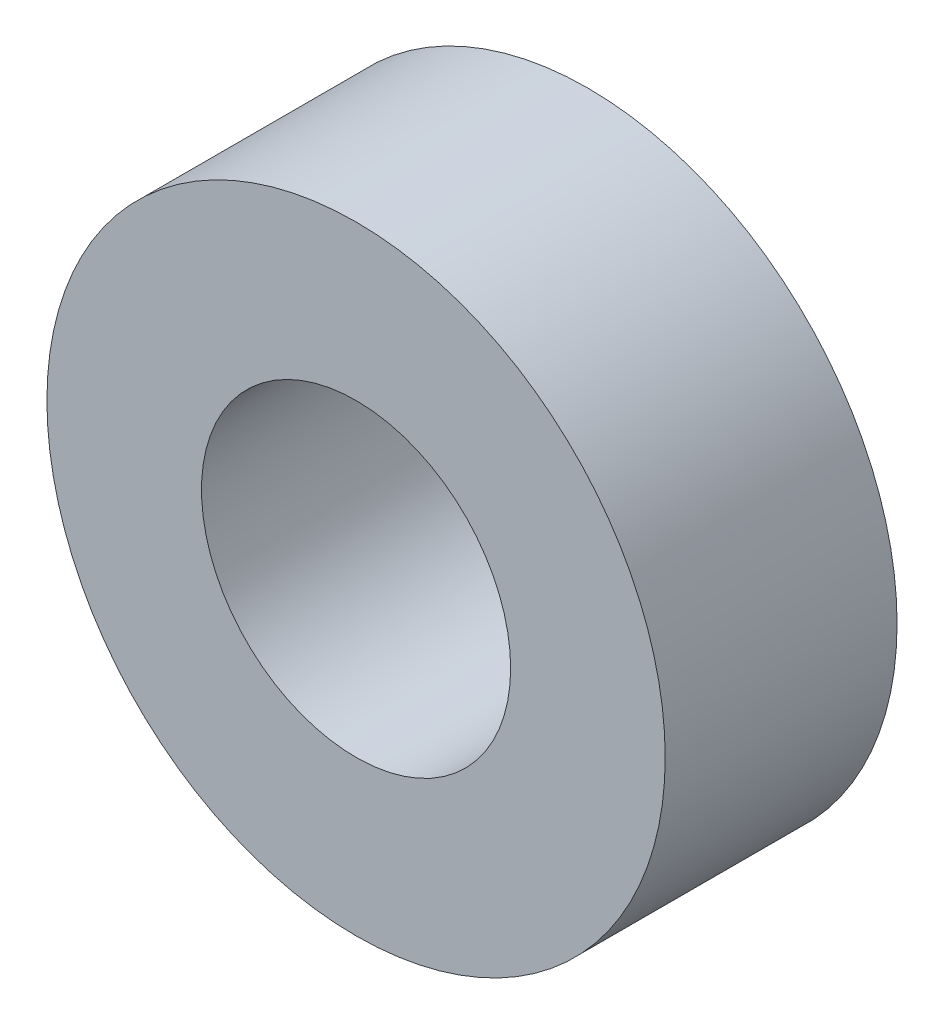
from build123d import *

# Parameters (mm, degrees)
SKETCH_1_R      = 6
SKETCH_1_R_2    = 3
EXTRUDE_1_DEPTH = 4.5


with BuildPart() as part:
    # 草图1 → 凸台-拉伸1 (new body)
    with BuildSketch(Plane.XY):
        Circle(SKETCH_1_R)
        Circle(SKETCH_1_R_2, mode=Mode.SUBTRACT)
    extrude(amount=EXTRUDE_1_DEPTH)


solid = part.part
